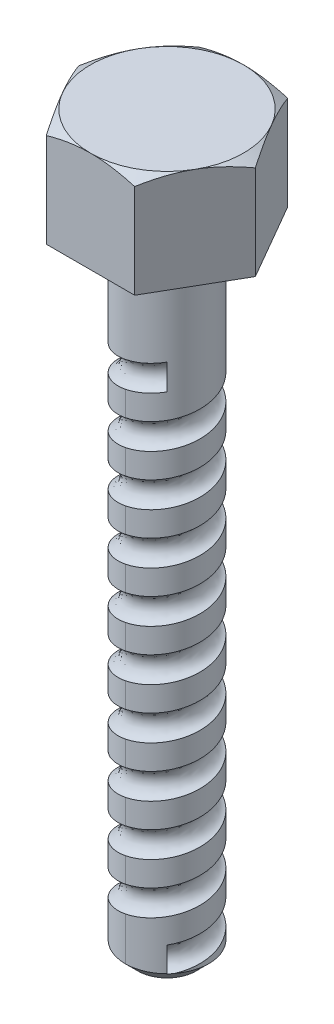
from build123d import *

# Parameters (mm, degrees)
BOSS_EXTRUDE1_DEPTH    = 8
SKETCH2_OUTSIDE_W      = 47.748
SKETCH2_OUTSIDE_H      = 45.872
SKETCH2_OUTSIDE_R      = 6.062177826
CUT_EXTRUDE2_DEPTH     = 8
CUT_EXTRUDE2_TAPER     = 60
SKETCH3_R              = 3.3
BOSS_EXTRUDE2_DEPTH    = 50
FILLET1_R              = 1
CHAMFER1_SIZE          = 1
CUT_SWEEP1_PITCH       = 4
CUT_SWEEP1_HEIGHT      = 40
CUT_SWEEP1_RADIUS      = 3.3
CUT_SWEEP1_START_ANGLE = 45


with BuildPart() as part:
    # Sketch1 → Boss-Extrude1 (new body)
    with BuildSketch(Plane(origin=(0, 0, 0), x_dir=(1, 0, 0), z_dir=(0, 1, 0))):
        Polygon((-7, 0), (-3.5, -6.062177826), (3.5, -6.062177826), (7, 0), (3.5, 6.062177826), (-3.5, 6.062177826), align=None)
    extrude(amount=BOSS_EXTRUDE1_DEPTH)

    # Sketch2 outside → Cut-Extrude2 (cut)
    with BuildSketch(Plane(origin=(0, 8, 0), x_dir=(1, 0, 0), z_dir=(0, 1, 0))):
        Rectangle(SKETCH2_OUTSIDE_W, SKETCH2_OUTSIDE_H)
        Circle(SKETCH2_OUTSIDE_R, mode=Mode.SUBTRACT)
    extrude(amount=-CUT_EXTRUDE2_DEPTH, taper=CUT_EXTRUDE2_TAPER, mode=Mode.SUBTRACT)

    # Sketch3 → Boss-Extrude2 (add)
    with BuildSketch(Plane.XZ):
        Circle(SKETCH3_R)
    extrude(amount=BOSS_EXTRUDE2_DEPTH)

    # Fillet1
    fillet1_edges = [part.edges().sort_by_distance(p)[0] for p in [
        (-3.3, 0, 0),
    ]]
    fillet(fillet1_edges, radius=FILLET1_R)

    # Chamfer1
    chamfer1_edges = [part.edges().sort_by_distance(p)[0] for p in [
        (-3.3, -50, 0),
    ]]
    chamfer(chamfer1_edges, length=CHAMFER1_SIZE)

    # Cut-Sweep1: sweep along a helix
    with BuildLine() as cut_sweep1_path:
        add(Helix(CUT_SWEEP1_PITCH, CUT_SWEEP1_HEIGHT, CUT_SWEEP1_RADIUS, center=(0, -50, 0), direction=(0, 1, 0), mode=Mode.PRIVATE).rotate(Axis((0, -50, 0), (0, 1, 0)), CUT_SWEEP1_START_ANGLE))
    # Sketch5 → Cut-Sweep1 (sweep, cut)
    with BuildSketch(Plane(origin=(0, 0, 0), x_dir=(0, 0, -1), z_dir=(1, 0, 0))):
        with BuildLine():
            Line((-4.506225775, -23.055196504), (-3.296735582, -23.531781726))
            ThreePointArc((-3.296735582, -23.531781726), (-2.6, -24.555196504), (-3.296735582, -25.578611283))
            Line((-3.296735582, -25.578611283), (-4.506225775, -26.055196504))
            Line((-4.506225775, -26.055196504), (-4.506225775, -23.055196504))
        make_face()
    sweep(path=cut_sweep1_path.line, is_frenet=True, mode=Mode.SUBTRACT)


solid = part.part
